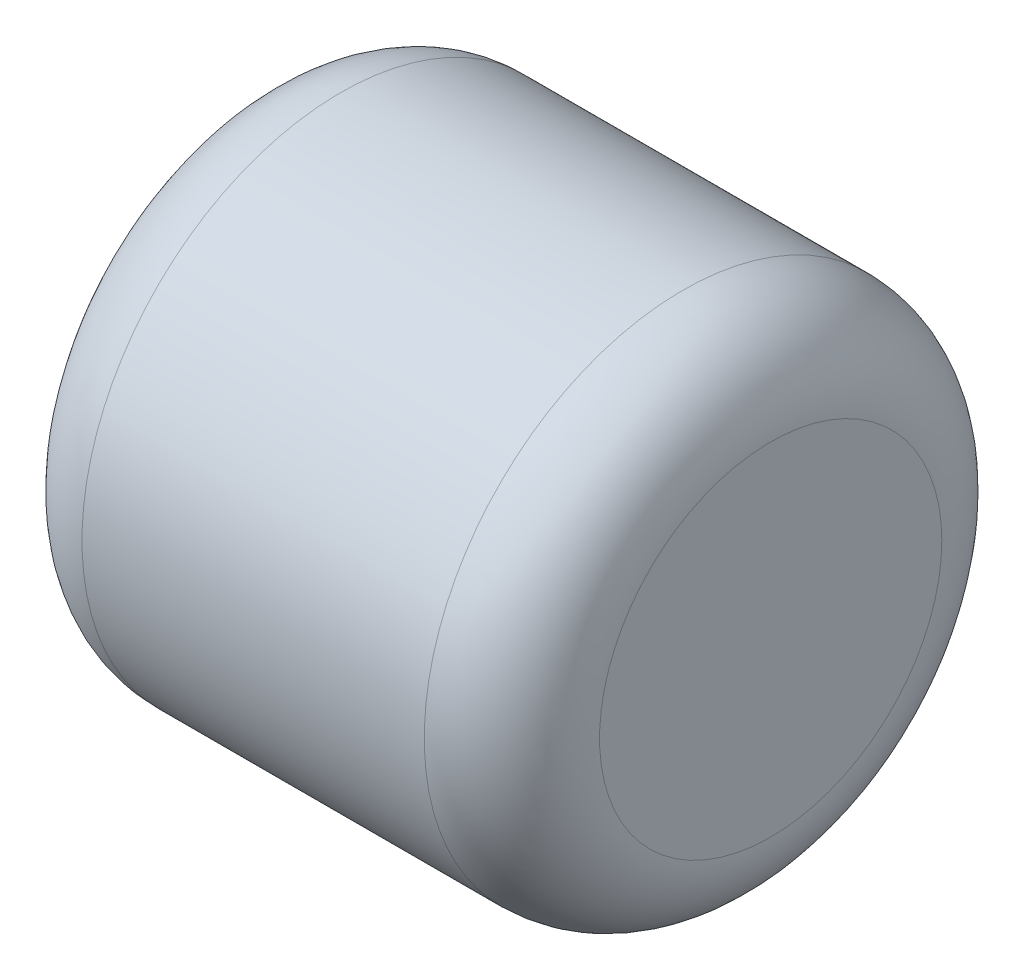
from build123d import *

# Parameters (mm, degrees)
SKETCH1_R      = 1.5
EXTRUDE1_DEPTH = 3
FILLET1_R      = 0.508


with BuildPart() as part:
    # Sketch1 → Extrude1 (new body)
    with BuildSketch(Plane(origin=(0, 0, 0), x_dir=(0, 0, -1), z_dir=(1, 0, 0))):
        Circle(SKETCH1_R)
    extrude(amount=EXTRUDE1_DEPTH)

    # Fillet1
    fillet1_edges = [part.edges().sort_by_distance(p)[0] for p in [
        (0, 0, 1.5),
        (3, 0, 1.5),
    ]]
    fillet(fillet1_edges, radius=FILLET1_R)


solid = part.part
